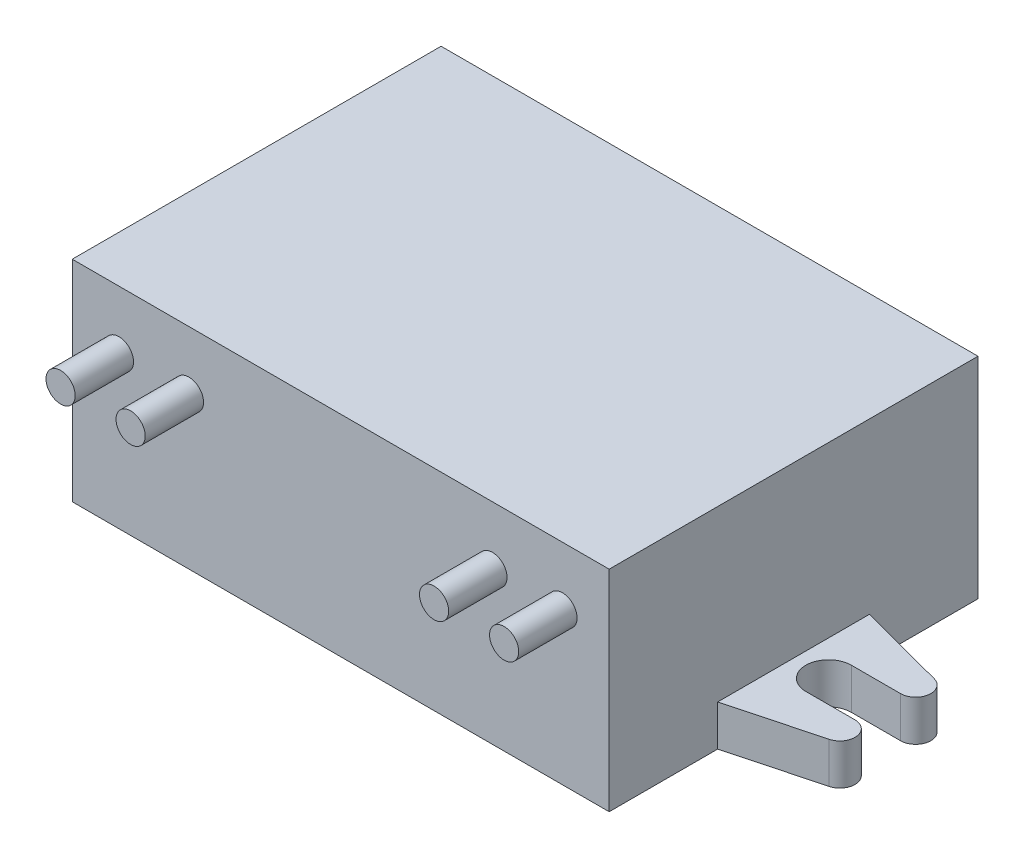
from build123d import *

# Parameters (mm, degrees)
BOSS_EXTRUDE1_DEPTH = 18
BOSS_EXTRUDE2_DEPTH = 3.5
SKETCH2_R           = 1.25
BOSS_EXTRUDE3_DEPTH = 5


with BuildPart() as part:
    # Sketch1 → Boss-Extrude1 (new body)
    with BuildSketch(Plane(origin=(0, 0, 0), x_dir=(1, 0, 0), z_dir=(0, 1, 0))):
        Polygon((23, -6.5), (23, 6.5), (23, 15.8), (-23, 15.8), (-23, 6.5), (-23, -6.5), (-23, -15.8), (23, -15.8), align=None)
    extrude(amount=BOSS_EXTRUDE1_DEPTH)

    # Sketch1_3 → Boss-Extrude2 (add)
    with BuildSketch(Plane(origin=(0, 0, 0), x_dir=(1, 0, 0), z_dir=(0, 1, 0))):
        with BuildLine():
            Line((30.546403177, 4.5), (23, 6.5))
            Line((23, 6.5), (23, -6.5))
            Line((23, -6.5), (30.546403177, -4.5))
            ThreePointArc((30.546403177, -4.5), (31.5, -3.079144467), (30.214227812, -1.95))
            Line((30.214227812, -1.95), (26, -1.95))
            ThreePointArc((26, -1.95), (24.05, 0), (26, 1.95))
            Line((26, 1.95), (30.214227812, 1.95))
            ThreePointArc((30.214227812, 1.95), (31.5, 3.079144467), (30.546403177, 4.5))
        make_face()
        with BuildLine():
            Line((-23, -6.5), (-23, 6.5))
            Line((-23, 6.5), (-30.546403177, 4.5))
            ThreePointArc((-30.546403177, 4.5), (-31.5, 3.079144467), (-30.214227812, 1.95))
            Line((-30.214227812, 1.95), (-26, 1.95))
            ThreePointArc((-26, 1.95), (-24.05, 0), (-26, -1.95))
            Line((-26, -1.95), (-30.214227812, -1.95))
            ThreePointArc((-30.214227812, -1.95), (-31.5, -3.079144467), (-30.546403177, -4.5))
            Line((-30.546403177, -4.5), (-23, -6.5))
        make_face()
    extrude(amount=BOSS_EXTRUDE2_DEPTH)

    # Sketch2 → Boss-Extrude3 (add)
    with BuildSketch(Plane.XY.offset(15.8)):
        with Locations((19, 13)):
            Circle(SKETCH2_R)
        with Locations((13, 13)):
            Circle(SKETCH2_R)
        with Locations((-19, 13)):
            Circle(SKETCH2_R)
        with Locations((-13, 13)):
            Circle(SKETCH2_R)
    extrude(amount=BOSS_EXTRUDE3_DEPTH)


solid = part.part
